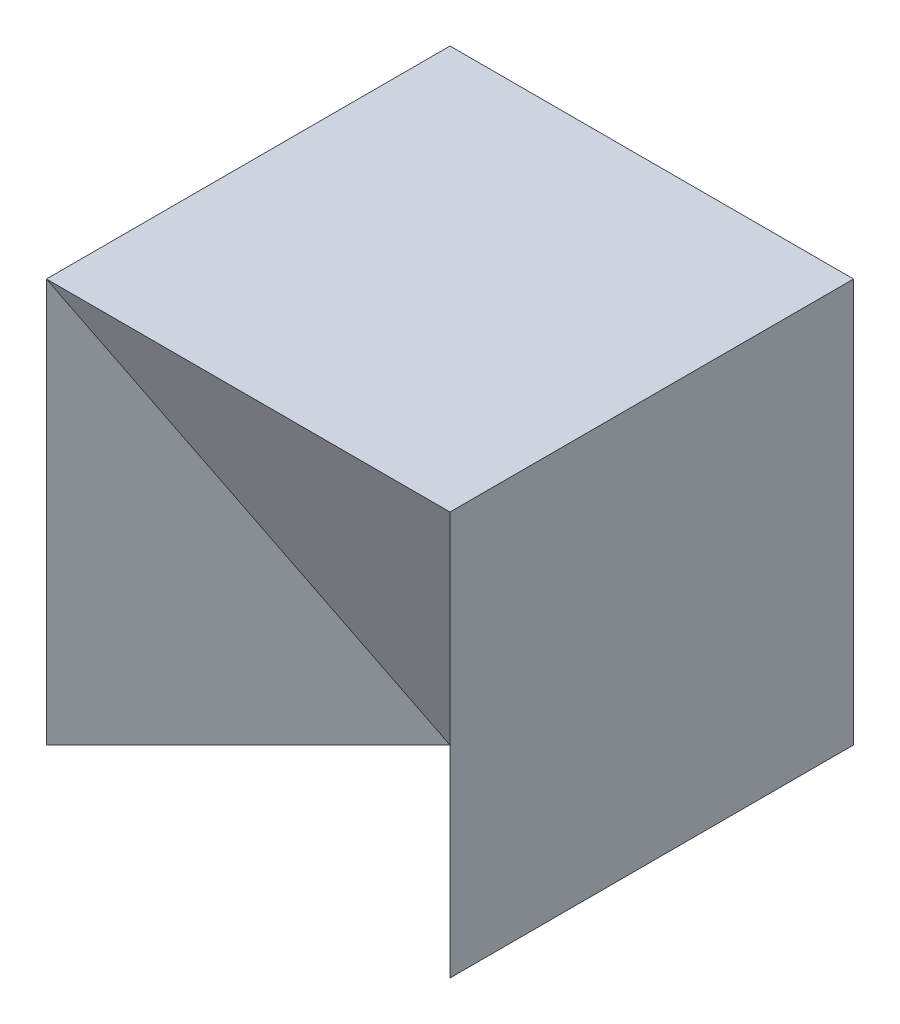
from build123d import *

# Parameters (mm, degrees)
SKETCH2_W           = 4
SKETCH2_H           = 4
BOSS_EXTRUDE1_DEPTH = 4
CUT_EXTRUDE2_DEPTH  = 10


with BuildPart() as part:
    # Sketch2 → Boss-Extrude1 (new body)
    with BuildSketch(Plane(origin=(0, 0, 0), x_dir=(1, 0, 0), z_dir=(0, 1, 0))):
        Rectangle(SKETCH2_W, SKETCH2_H)
    extrude(amount=BOSS_EXTRUDE1_DEPTH)

    # 3DSketch2 → Cut-Extrude2 (cut, along a direction that is not the sketch's normal)
    with BuildSketch(Plane(origin=(-2, 4, 2), x_dir=(0.40824829046386296, -0.8164965809277261, -0.4082482904638631), z_dir=(0, -0.447213595499958, 0.894427190999916))):
        Polygon((0, 0), (4.898979486, 0), (1.632993162, 3.651483717), align=None)
    extrude(amount=CUT_EXTRUDE2_DEPTH, dir=(0, -1, 0), mode=Mode.SUBTRACT)


solid = part.part
